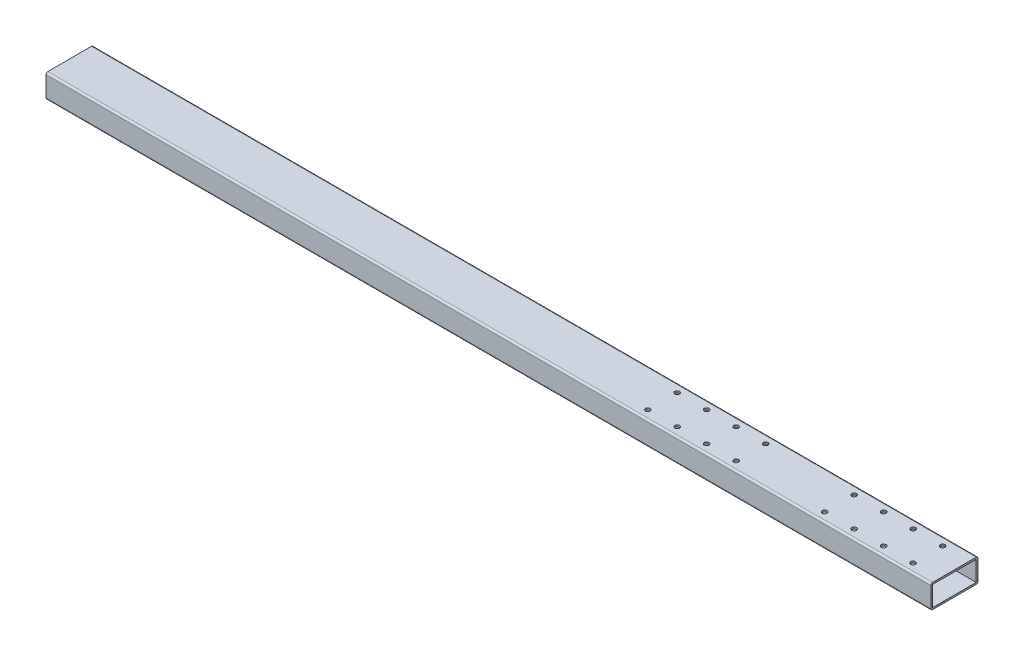
from build123d import *

# Parameters (mm, degrees)
SKETCH_1_W          = 74
SKETCH_1_H          = 34
EXTRUDE_1_DEPTH     = 1500
SKETCH_2_R          = 4.05
CUT_EXTRUDE_1_DEPTH = 41


with BuildPart() as part:
    # Эскиз1 → Вытянуть-Тонкостенный1 (new body)
    with BuildSketch(Plane(origin=(0, 0, 0), x_dir=(0, 0, -1), z_dir=(1, 0, 0))):
        with BuildLine():
            Line((40, 17), (40, -17))
            ThreePointArc((40, -17), (39.121320344, -19.121320344), (37, -20))
            Line((37, -20), (-37, -20))
            ThreePointArc((-37, -20), (-39.121320344, -19.121320344), (-40, -17))
            Line((-40, -17), (-40, 17))
            ThreePointArc((-40, 17), (-39.121320344, 19.121320344), (-37, 20))
            Line((-37, 20), (37, 20))
            ThreePointArc((37, 20), (39.121320344, 19.121320344), (40, 17))
        make_face()
        Rectangle(SKETCH_1_W, SKETCH_1_H, mode=Mode.SUBTRACT)
    extrude(amount=EXTRUDE_1_DEPTH)

    # Эскиз2 → Вырез-Вытянуть1 (cut, through all)
    with BuildSketch(Plane(origin=(0, 20, 0), x_dir=(1, 0, 0), z_dir=(0, 1, 0))):
        with Locations((1455, -25)):
            Circle(SKETCH_2_R)
        with Locations((1405, -25)):
            Circle(SKETCH_2_R)
        with Locations((1355, -25)):
            Circle(SKETCH_2_R)
        with Locations((1305, -25)):
            Circle(SKETCH_2_R)
        with Locations((1155, -25)):
            Circle(SKETCH_2_R)
        with Locations((1105, -25)):
            Circle(SKETCH_2_R)
        with Locations((1055, -25)):
            Circle(SKETCH_2_R)
        with Locations((1005, -25)):
            Circle(SKETCH_2_R)
        with Locations((1005, 25)):
            Circle(SKETCH_2_R)
        with Locations((1055, 25)):
            Circle(SKETCH_2_R)
        with Locations((1105, 25)):
            Circle(SKETCH_2_R)
        with Locations((1155, 25)):
            Circle(SKETCH_2_R)
        with Locations((1305, 25)):
            Circle(SKETCH_2_R)
        with Locations((1355, 25)):
            Circle(SKETCH_2_R)
        with Locations((1405, 25)):
            Circle(SKETCH_2_R)
        with Locations((1455, 25)):
            Circle(SKETCH_2_R)
    extrude(amount=-CUT_EXTRUDE_1_DEPTH, mode=Mode.SUBTRACT)


solid = part.part
